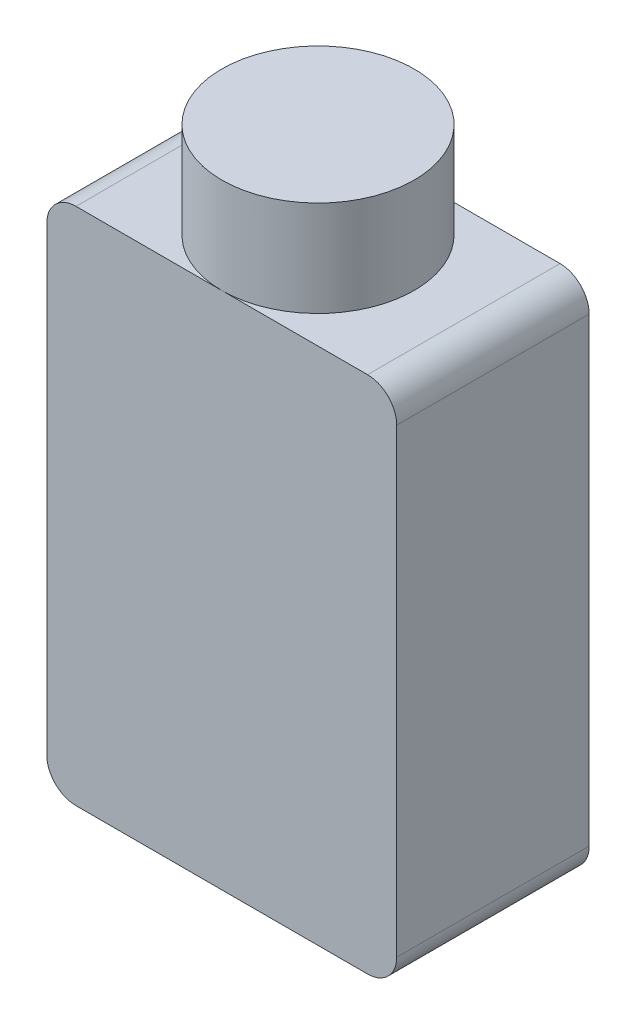
from build123d import *

# Parameters (mm, degrees)
SKETCH1_W           = 38.1
SKETCH1_H           = 20.955
BOSS_EXTRUDE1_DEPTH = 56.515
FILLET1_R           = 3.175
SKETCH2_R           = 10.4775
BOSS_EXTRUDE2_DEPTH = 10.414


with BuildPart() as part:
    # Sketch1 → Boss-Extrude1 (new body)
    with BuildSketch(Plane(origin=(0, 0, 0), x_dir=(1, 0, 0), z_dir=(0, 1, 0))):
        Rectangle(SKETCH1_W, SKETCH1_H)
    extrude(amount=BOSS_EXTRUDE1_DEPTH)

    # Fillet1
    fillet1_edges = [part.edges().sort_by_distance(p)[0] for p in [
        (-19.05, 56.515, 0),
        (19.05, 56.515, 0),
        (-19.05, 0, 0),
        (19.05, 0, 0),
    ]]
    fillet(fillet1_edges, radius=FILLET1_R)

    # Sketch2 → Boss-Extrude2 (add)
    with BuildSketch(Plane(origin=(0, 56.515, 0), x_dir=(1, 0, 0), z_dir=(0, 1, 0))):
        Circle(SKETCH2_R)
    extrude(amount=BOSS_EXTRUDE2_DEPTH)


solid = part.part
